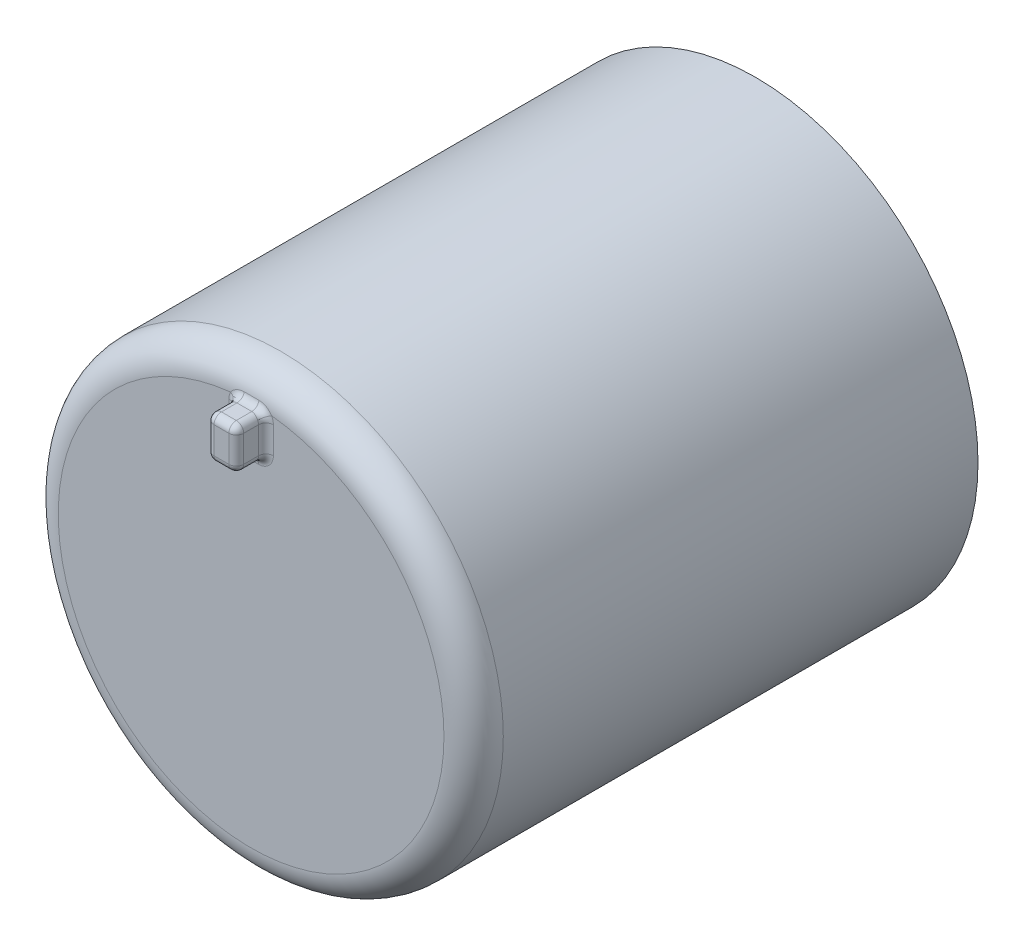
from build123d import *

# Parameters (mm, degrees)
ESQUISSE1_R        = 7.5
ESQUISSE1_R_2      = 2.75
BOSS_EXTRU_1_DEPTH = 15
ESQUISSE2_R        = 7.5
BOSS_EXTRU_2_DEPTH = 2
CONG_1_R           = 1
ESQUISSE3_W        = 1
ESQUISSE3_H        = 1.40589343
BOSS_EXTRU_3_DEPTH = 1
CONG_2_R           = 0.25
CONG_3_R           = 0.25


with BuildPart() as part:
    # Esquisse1 → Boss.-Extru.1 (new body)
    with BuildSketch(Plane.XY):
        Circle(ESQUISSE1_R)
        Circle(ESQUISSE1_R_2, mode=Mode.SUBTRACT)
    extrude(amount=BOSS_EXTRU_1_DEPTH)

    # Esquisse2 → Boss.-Extru.2 (add)
    with BuildSketch(Plane.XY.offset(15)):
        Circle(ESQUISSE2_R)
    extrude(amount=BOSS_EXTRU_2_DEPTH)

    # Congé1
    cong_1_edges = [part.edges().sort_by_distance(p)[0] for p in [
        (-7.5, 0, 17),
    ]]
    fillet(cong_1_edges, radius=CONG_1_R)

    # Esquisse3 → Boss.-Extru.3 (add)
    with BuildSketch(Plane.XY.offset(17)):
        with Locations((0, 5.777793983)):
            Rectangle(ESQUISSE3_W, ESQUISSE3_H)
    extrude(amount=BOSS_EXTRU_3_DEPTH)

    # Congé2
    cong_2_edges = [part.edges().sort_by_distance(p)[0] for p in [
        (-0.5, 6.480740698, 17.5),
        (-0.5, 5.074847268, 17.5),
        (0.5, 5.074847268, 17.5),
        (0.5, 6.480740698, 17.5),
        (-0.5, 5.777793983, 18),
        (0, 5.074847268, 18),
        (0.5, 5.777793983, 18),
        (0, 6.480740698, 18),
    ]]
    fillet(cong_2_edges, radius=CONG_2_R)

    # Congé3
    cong_3_edges = [part.edges().sort_by_distance(p)[0] for p in [
        (0, 6.480740698, 17),
        (-0.5, 5.777793983, 17),
        (0.5, 5.777793983, 17),
        (0, 5.074847268, 17),
        (-0.426776695, 6.407517394, 17),
        (0.426776695, 6.407517394, 17),
        (-0.426776695, 5.148070573, 17),
        (0.426776695, 5.148070573, 17),
    ]]
    fillet(cong_3_edges, radius=CONG_3_R)


solid = part.part
